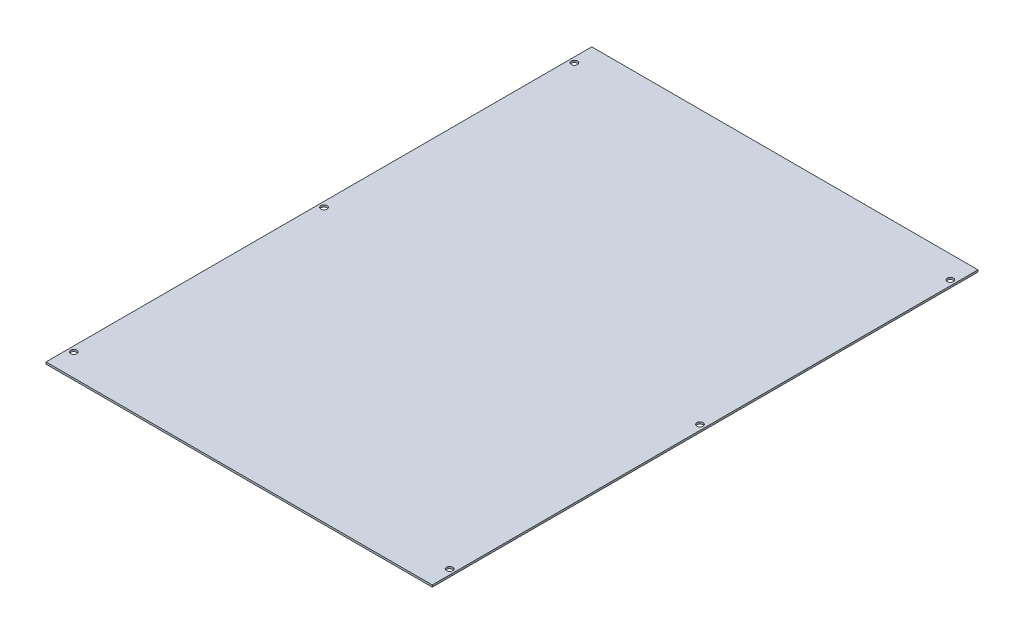
from build123d import *

# Parameters (mm, degrees)
SKETCH1_W                  = 318.5
SKETCH1_H                  = 450
BOSS_EXTRUDE1_DEPTH        = 1.6002
F_10_CLEARANCE_HOLE1_D     = 5.1054
F_10_CLEARANCE_HOLE1_DEPTH = 129.53
F_10_CLEARANCE_HOLE1_TIP   = 1.533816902


with BuildPart() as part:
    # Sketch1 → Boss-Extrude1 (new body)
    with BuildSketch(Plane(origin=(0, 0, 0), x_dir=(1, 0, 0), z_dir=(0, 1, 0))):
        Rectangle(SKETCH1_W, SKETCH1_H)
    extrude(amount=BOSS_EXTRUDE1_DEPTH)

    # #10 Clearance Hole1
    with Locations(Plane(origin=(0, 1.6002, 0), x_dir=(1, 0, 0), z_dir=(0, 1, 0))):
        with Locations((-155, 206.45), (155, 206.45), (155, 0), (155, -206.45), (-155, -206.45), (-155, 0)):
            Hole(F_10_CLEARANCE_HOLE1_D / 2, depth=F_10_CLEARANCE_HOLE1_DEPTH)
            with Locations((0, 0, -(F_10_CLEARANCE_HOLE1_DEPTH + F_10_CLEARANCE_HOLE1_TIP / 2))):  # 118° drill point
                Cone(0, F_10_CLEARANCE_HOLE1_D / 2, F_10_CLEARANCE_HOLE1_TIP, mode=Mode.SUBTRACT)


solid = part.part
